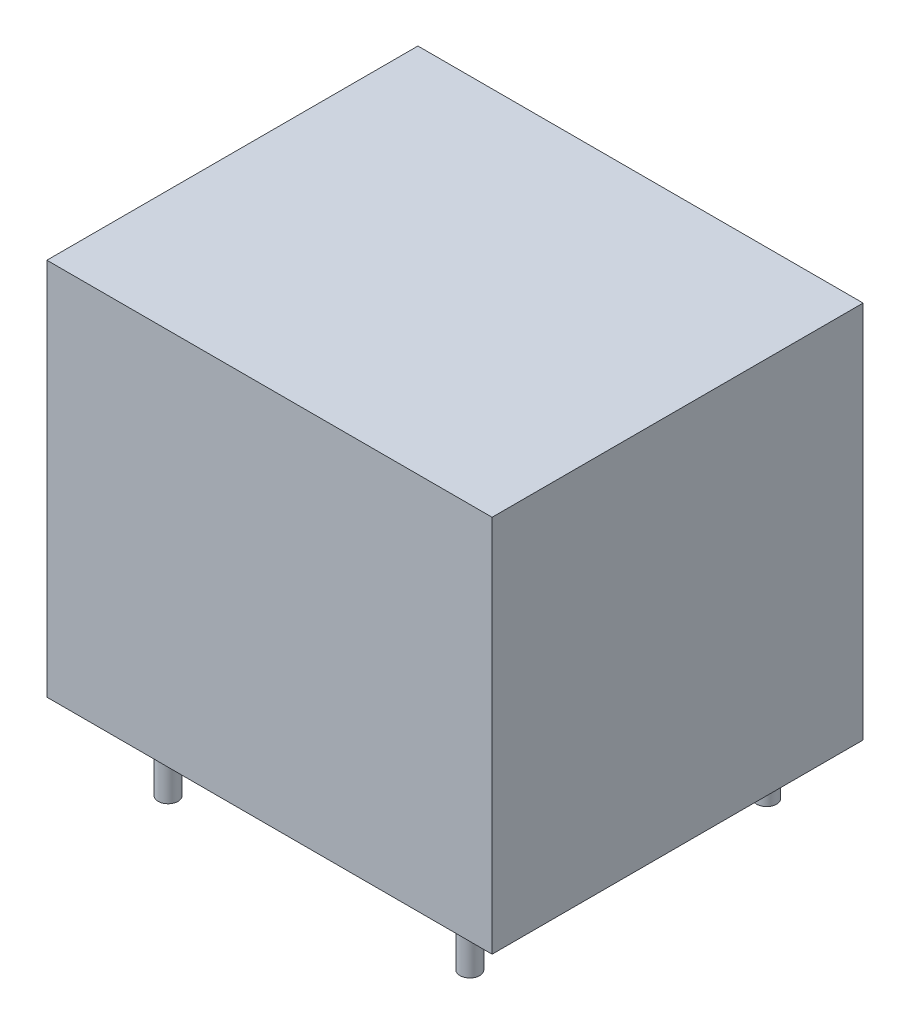
from build123d import *

# Parameters (mm, degrees)
ESQUISSE1_W        = 18
ESQUISSE1_H        = 15
BOSS_EXTRU_1_DEPTH = 15.3
ESQUISSE2_R        = 0.4
BOSS_EXTRU_2_DEPTH = 2.5


with BuildPart() as part:
    # Esquisse1 → Boss.-Extru.1 (new body)
    with BuildSketch(Plane(origin=(0, 0, 0), x_dir=(1, 0, 0), z_dir=(0, 1, 0))):
        Rectangle(ESQUISSE1_W, ESQUISSE1_H)
    extrude(amount=BOSS_EXTRU_1_DEPTH)

    # Esquisse2 → Boss.-Extru.2 (add)
    with BuildSketch(Plane(origin=(0, 0, 0), x_dir=(-1, 0, 0), z_dir=(0, -1, 0))):
        with Locations(Location((7.6, 0, 0), (0, 0, 270))):  # turned: the seam where the file's is
            Circle(ESQUISSE2_R)
        with Locations(Location((5.6, -6, 0), (0, 0, 270))):  # turned: the seam where the file's is
            Circle(ESQUISSE2_R)
        with Locations(Location((5.6, 6, 0), (0, 0, 270))):  # turned: the seam where the file's is
            Circle(ESQUISSE2_R)
        with Locations(Location((-6.6, -6, 0), (0, 0, 270))):  # turned: the seam where the file's is
            Circle(ESQUISSE2_R)
        with Locations(Location((-6.6, 6, 0), (0, 0, 270))):  # turned: the seam where the file's is
            Circle(ESQUISSE2_R)
    extrude(amount=BOSS_EXTRU_2_DEPTH)


solid = part.part
